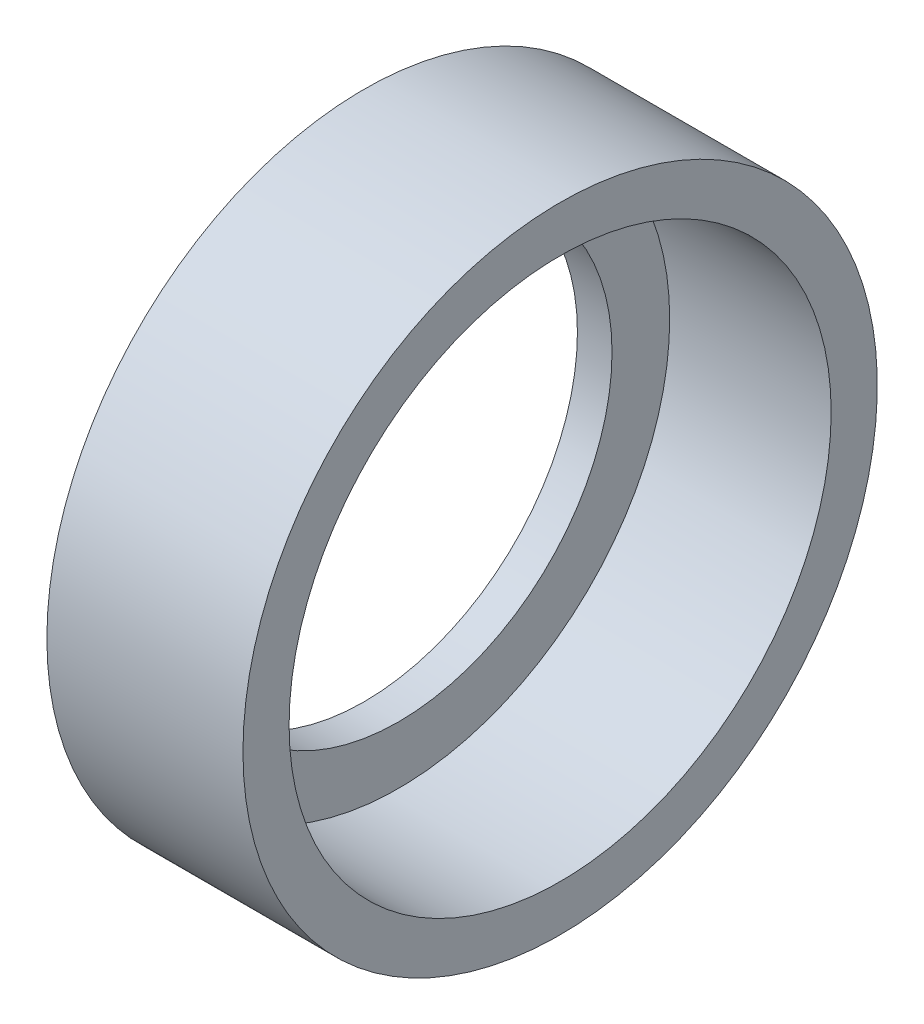
from build123d import *


with BuildPart() as part:
    # Эскиз1 → Повернуть1 (revolve)
    with BuildSketch(Plane(origin=(0, 0, 0), x_dir=(1, 0, 0), z_dir=(0, 1, 0))):
        Polygon((0, 23.5), (-14, 23.5), (-14, 18.5), (-17, 18.5), (-17, 27.5), (0, 27.5), align=None)
    revolve(axis=Axis((-1000, 0, 0), (1, 0, 0)))


solid = part.part
